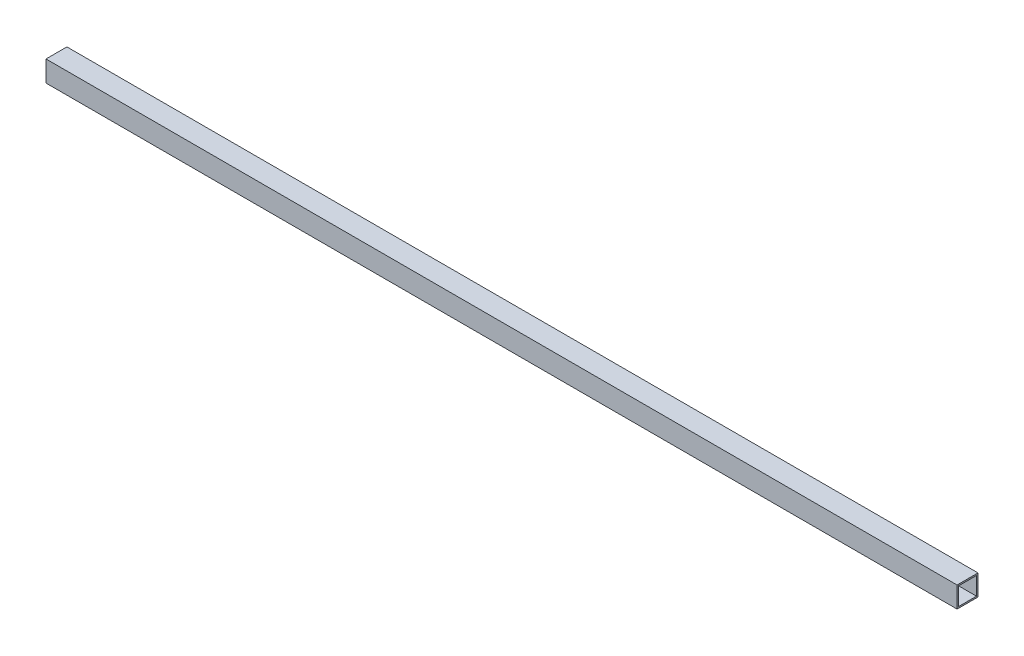
from build123d import *

# Parameters (mm, degrees)
SKETCH1_W           = 44.45
SKETCH1_H           = 44.45
SKETCH1_W_2         = 38.1
SKETCH1_H_2         = 38.1
BOSS_EXTRUDE1_DEPTH = 1936.75


with BuildPart() as part:
    # Sketch1 → Boss-Extrude1 (new body)
    with BuildSketch(Plane(origin=(0, 0, 0), x_dir=(0, 0, -1), z_dir=(1, 0, 0))):
        with Locations((22.225, 22.225)):
            Rectangle(SKETCH1_W, SKETCH1_H)
        with Locations((22.225, 22.225)):
            Rectangle(SKETCH1_W_2, SKETCH1_H_2, mode=Mode.SUBTRACT)
    extrude(amount=BOSS_EXTRUDE1_DEPTH)


solid = part.part
